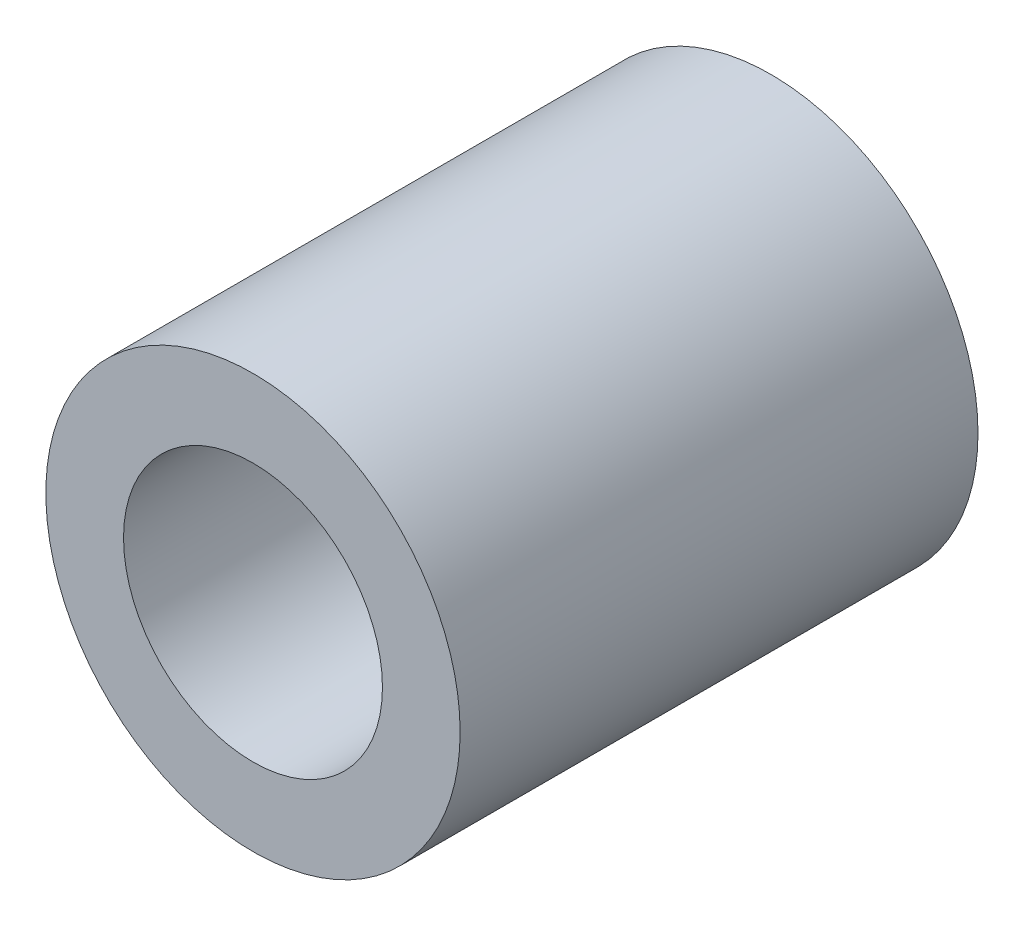
from build123d import *

# Parameters (mm, degrees)
CROQUIS1_R              = 4
CROQUIS1_R_2            = 2.5
SALIENTE_EXTRUIR1_DEPTH = 10


with BuildPart() as part:
    # Croquis1 → Saliente-Extruir1 (new body)
    with BuildSketch(Plane.XY):
        Circle(CROQUIS1_R)
        Circle(CROQUIS1_R_2, mode=Mode.SUBTRACT)
    extrude(amount=SALIENTE_EXTRUIR1_DEPTH)


solid = part.part
